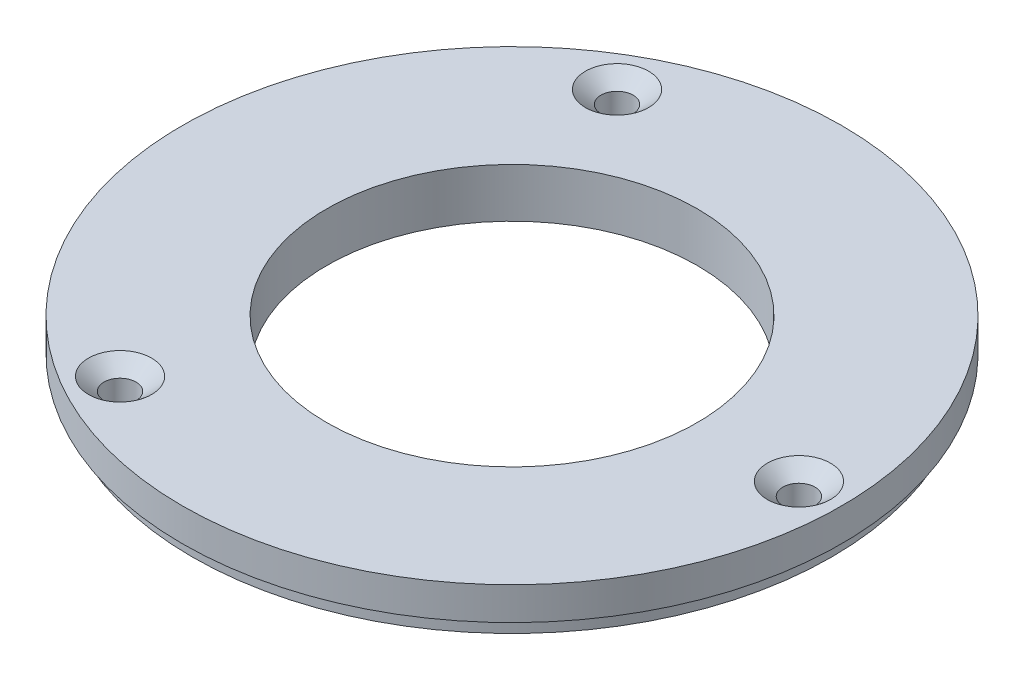
from build123d import *

# Parameters (mm, degrees)
SKETCH1_R                                          = 51.054
SKETCH1_R_2                                        = 28.702
BOSS_EXTRUDE1_DEPTH                                = 7.62
CSK_FOR_10_FLAT_HEAD_MACHINE_SCREW_100_D           = 4.9784
CSK_FOR_10_FLAT_HEAD_MACHINE_SCREW_100_CSINK_D     = 9.779
CSK_FOR_10_FLAT_HEAD_MACHINE_SCREW_100_CSINK_ANGLE = 100
CIRPATTERN1_COUNT                                  = 3
SKETCH6_R                                          = 51.054
SKETCH6_R_2                                        = 49.53
CUT_EXTRUDE1_DEPTH                                 = 2.54


with BuildPart() as part:
    # Sketch1 → Boss-Extrude1 (new body)
    with BuildSketch(Plane(origin=(0, 0, 0), x_dir=(1, 0, 0), z_dir=(0, 1, 0))):
        with Locations(Location((0, 0, 0), (0, 0, 90))):
            Circle(SKETCH1_R)
        with Locations(Location((0, 0, 0), (0, 0, 90))):
            Circle(SKETCH1_R_2, mode=Mode.SUBTRACT)
    extrude(amount=BOSS_EXTRUDE1_DEPTH)

    # CSK for #10 Flat Head Machine Screw (100)1 (through all)
    with Locations(Plane(origin=(0, 7.62, 0), x_dir=(1, 0, 0), z_dir=(0, 1, 0))):
        with Locations((44.45, 0)):
            csk_for_10_flat_head_machine_screw_100 = CounterSinkHole(CSK_FOR_10_FLAT_HEAD_MACHINE_SCREW_100_D / 2, CSK_FOR_10_FLAT_HEAD_MACHINE_SCREW_100_CSINK_D / 2, counter_sink_angle=CSK_FOR_10_FLAT_HEAD_MACHINE_SCREW_100_CSINK_ANGLE)

    # CirPattern1: CSK for #10 Flat Head Machine Screw (100)1 ×3 about axis
    cirpattern1_axis = Axis((0, 0, 0), (0, 1, 0))
    for i in range(1, CIRPATTERN1_COUNT):
        add(csk_for_10_flat_head_machine_screw_100.rotate(cirpattern1_axis, i * 360 / CIRPATTERN1_COUNT), mode=Mode.SUBTRACT)

    # Sketch6 → Cut-Extrude1 (cut)
    with BuildSketch(Plane.XZ):
        with Locations(Location((0, 0, 0), (0, 0, 270))):
            Circle(SKETCH6_R)
        with Locations(Location((0, 0, 0), (0, 0, 270))):
            Circle(SKETCH6_R_2, mode=Mode.SUBTRACT)
    extrude(amount=-CUT_EXTRUDE1_DEPTH, mode=Mode.SUBTRACT)


solid = part.part
